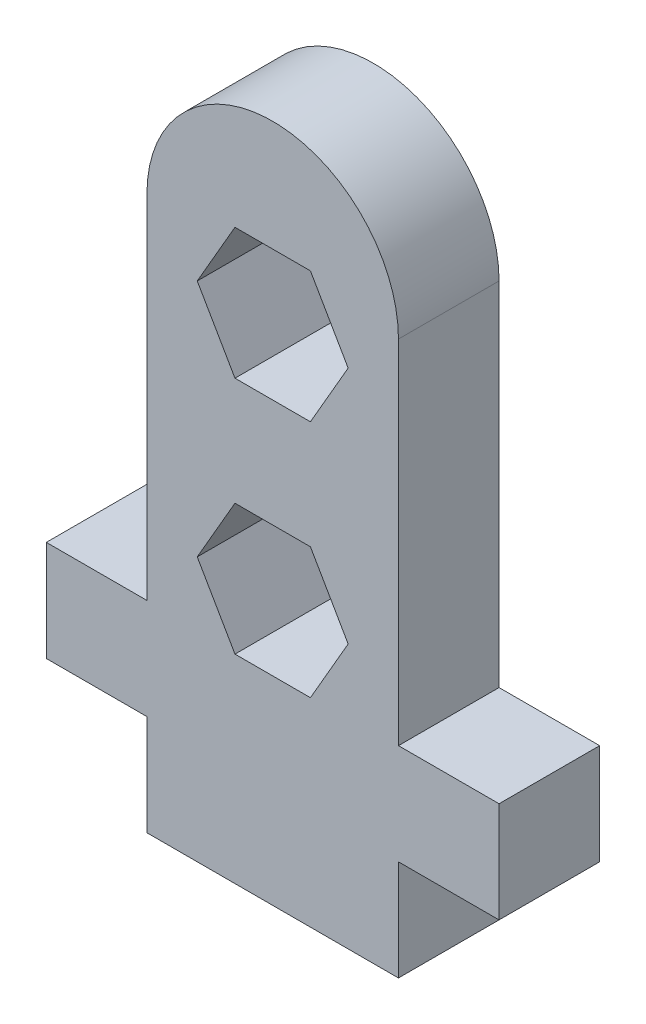
from build123d import *

# Parameters (mm, degrees)
BOSS_EXTRUDE1_DEPTH = 4


with BuildPart() as part:
    # Sketch1 → Boss-Extrude1 (new body)
    with BuildSketch(Plane.XY):
        with BuildLine():
            Line((0, 0), (10, 0))
            Line((10, 0), (10, 4))
            Line((10, 4), (14, 4))
            Line((14, 4), (14, 8))
            Line((14, 8), (10, 8))
            Line((10, 8), (10, 22))
            ThreePointArc((10, 22), (5, 27), (0, 22))
            Line((0, 22), (0, 8))
            Line((0, 8), (-4, 8))
            Line((-4, 8), (-4, 4))
            Line((-4, 4), (0, 4))
            Line((0, 4), (0, 0))
        make_face()
        Polygon((3.5, 17.401923789), (6.5, 17.401923789), (8, 20), (6.5, 22.598076211), (3.5, 22.598076211), (2, 20), align=None, mode=Mode.SUBTRACT)
        Polygon((8, 10.5), (6.5, 13.098076211), (3.5, 13.098076211), (2, 10.5), (3.5, 7.901923789), (6.5, 7.901923789), align=None, mode=Mode.SUBTRACT)
    extrude(amount=BOSS_EXTRUDE1_DEPTH)


solid = part.part
